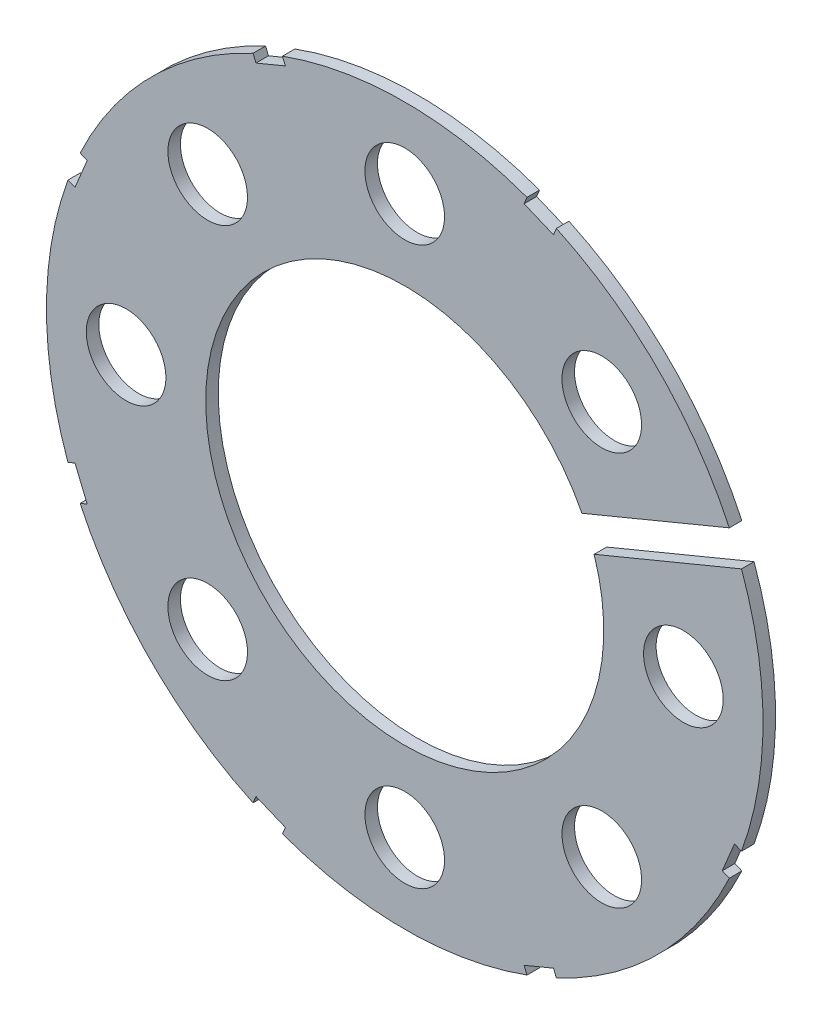
from build123d import *

# Parameters (mm, degrees)
SKETCH4_R           = 28.575
BOSS_EXTRUDE2_DEPTH = 1
SKETCH5_R           = 15.875
CUT_EXTRUDE5_DEPTH  = 2
SKETCH6_R           = 3.175
CUT_EXTRUDE6_DEPTH  = 2
CIRPATTERN1_COUNT   = 8
CUT_EXTRUDE11_DEPTH = 2


with BuildPart() as part:
    # Sketch4 → Boss-Extrude2 (new body)
    with BuildSketch(Plane.XY):
        Circle(SKETCH4_R)
    extrude(amount=BOSS_EXTRUDE2_DEPTH)

    # Sketch5 → Cut-Extrude5 (cut, through all)
    with BuildSketch(Plane.XY.offset(1)):
        Circle(SKETCH5_R)
    extrude(amount=-CUT_EXTRUDE5_DEPTH, mode=Mode.SUBTRACT)

    # Sketch6 → Cut-Extrude6 (cut, through all)
    with BuildSketch(Plane.XY.offset(1)):
        with Locations((22.225, 0)):
            Circle(SKETCH6_R)
    cut_extrude6 = extrude(amount=-CUT_EXTRUDE6_DEPTH, mode=Mode.SUBTRACT)

    # CirPattern1: Cut-Extrude6 ×8 about axis
    cirpattern1_axis = Axis((0, 0, 0), (0, 0, 1))
    for i in range(1, CIRPATTERN1_COUNT):
        add(cut_extrude6.rotate(cirpattern1_axis, i * 360 / CIRPATTERN1_COUNT), mode=Mode.SUBTRACT)

    # Sketch8 → Cut-Extrude11 (cut, through all)
    with BuildSketch(Plane.XY.offset(1)):
        Polygon((29.433830701, 13.566529963), (10.660598601, 5.790402618), (11.632614519, 3.443748605), (30.405846619, 11.219875951), align=None)
        Polygon((12.351510066, 26.500513186), (10.004856053, 27.472529104), (9.518848094, 26.299202097), (11.865502107, 25.327186179), align=None)
        Polygon((-10.004856053, 27.472529104), (-12.351510066, 26.500513186), (-11.865502107, 25.327186179), (-9.518848094, 26.299202097), align=None)
        Polygon((-26.500513186, 12.351510066), (-27.472529104, 10.004856053), (-26.299202097, 9.518848094), (-25.327186179, 11.865502107), align=None)
        Polygon((-27.472529104, -10.004856053), (-26.500513186, -12.351510066), (-25.327186179, -11.865502107), (-26.299202097, -9.518848094), align=None)
        Polygon((-12.351510066, -26.500513186), (-10.004856053, -27.472529104), (-9.518848094, -26.299202097), (-11.865502107, -25.327186179), align=None)
        Polygon((10.004856053, -27.472529104), (12.351510066, -26.500513186), (11.865502107, -25.327186179), (9.518848094, -26.299202097), align=None)
        Polygon((26.500513186, -12.351510066), (27.472529104, -10.004856053), (26.299202097, -9.518848094), (25.327186179, -11.865502107), align=None)
    extrude(amount=-CUT_EXTRUDE11_DEPTH, mode=Mode.SUBTRACT)


solid = part.part
